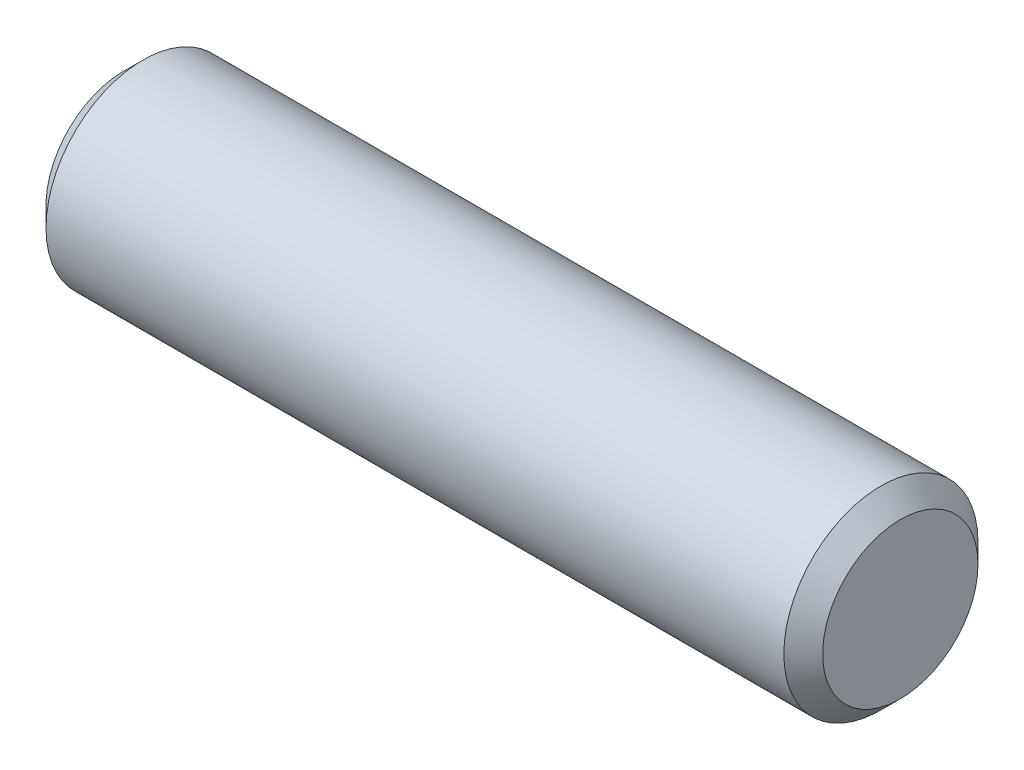
from build123d import *

# Parameters (mm, degrees)
SKETCH2_R           = 3.175
EXTRUDE1_DEPTH      = 12.7
EXTRUDE1_DEPTH_BACK = 12.7
CHAMFER1_SIZE       = 0.635


with BuildPart() as part:
    # Sketch2 → Extrude1 (new body, two sides)
    with BuildSketch(Plane(origin=(0, 0, 0), x_dir=(0, 0, -1), z_dir=(1, 0, 0))) as extrude1_sk:
        Circle(SKETCH2_R)
    extrude(amount=EXTRUDE1_DEPTH)
    extrude(extrude1_sk.sketch, amount=-EXTRUDE1_DEPTH_BACK)

    # Chamfer1
    chamfer1_edges = [part.edges().sort_by_distance(p)[0] for p in [
        (-12.7, 0, 3.175),
        (12.7, 0, 3.175),
    ]]
    chamfer(chamfer1_edges, length=CHAMFER1_SIZE)


solid = part.part
